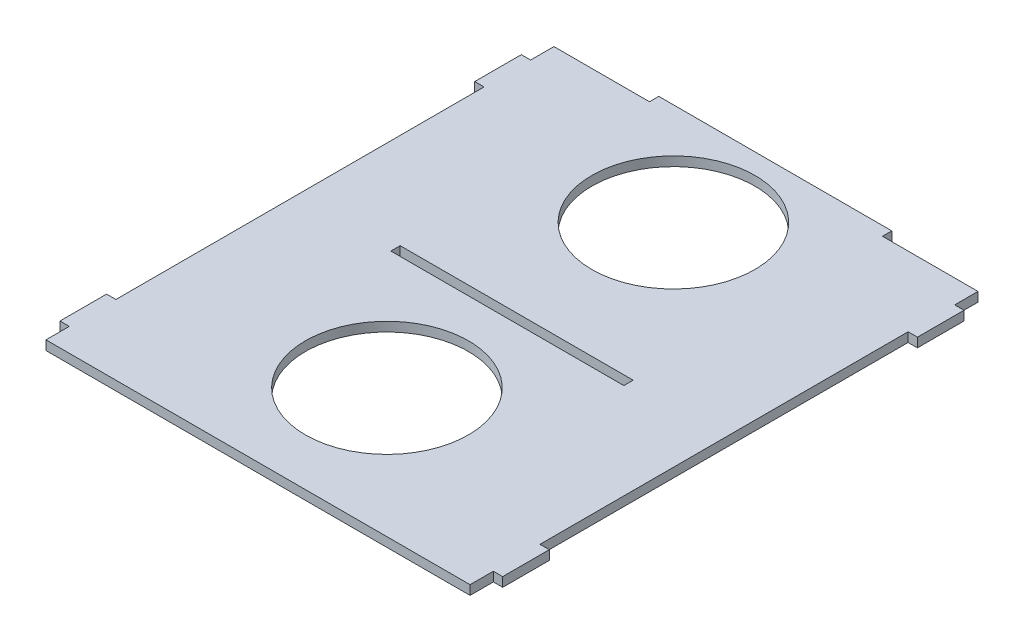
from build123d import *

# Parameters (mm, degrees)
SKETCH2_R           = 35
SKETCH2_W           = 100
SKETCH2_H           = 4
BOSS_EXTRUDE1_DEPTH = 4


with BuildPart() as part:
    # Sketch2 → Boss-Extrude1 (new body)
    with BuildSketch(Plane(origin=(0, 0, 0), x_dir=(1, 0, 0), z_dir=(0, 1, 0))):
        Polygon((-50, 84), (50, 84), (50, 80), (91, 80), (91, 70), (95, 70), (95, 50), (91, 50), (91, -108), (95, -108), (95, -128), (91, -128), (91, -138), (-91, -138), (-91, -128), (-95, -128), (-95, -108), (-91, -108), (-91, 50), (-95, 50), (-95, 70), (-91, 70), (-91, 80), (-50, 80), align=None)
        with Locations((0, 40.261243559)):
            Circle(SKETCH2_R, mode=Mode.SUBTRACT)
        with Locations((0, -82.68297303)):
            Circle(SKETCH2_R, mode=Mode.SUBTRACT)
        with Locations((0, -29)):
            Rectangle(SKETCH2_W, SKETCH2_H, mode=Mode.SUBTRACT)
    extrude(amount=BOSS_EXTRUDE1_DEPTH)


solid = part.part
